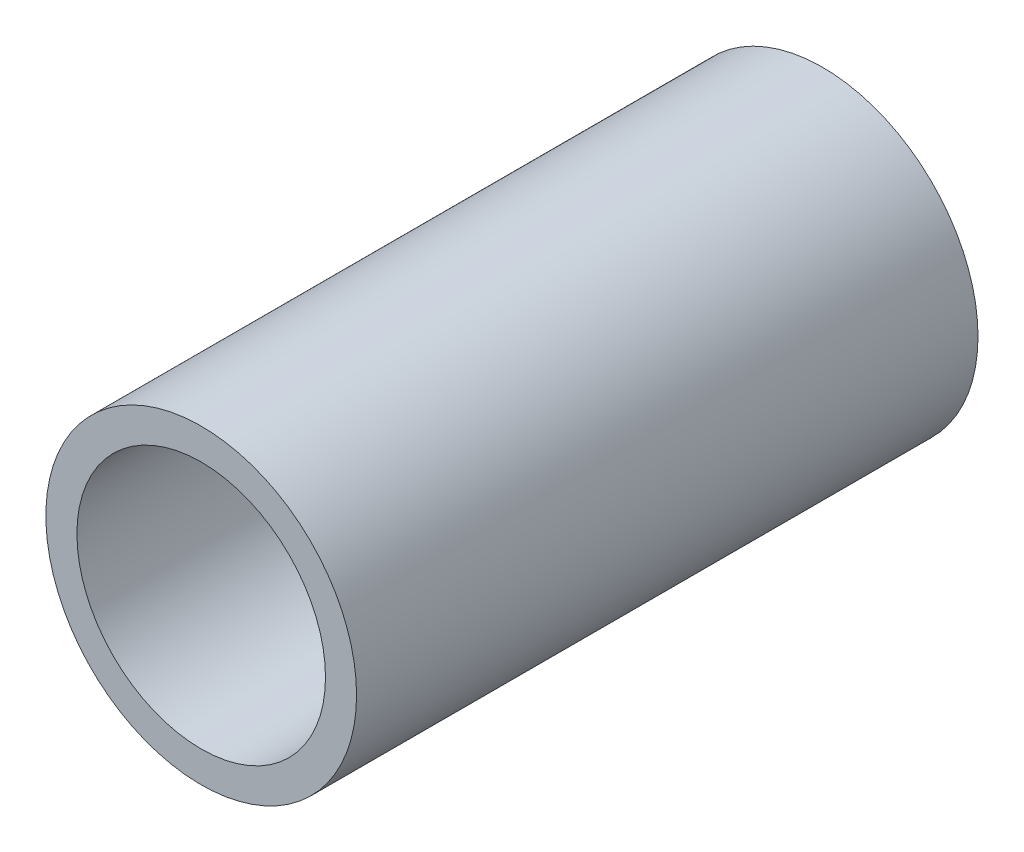
from build123d import *

# Parameters (mm, degrees)
SKETCH1_R           = 1.25
SKETCH1_R_2         = 1
BOSS_EXTRUDE1_DEPTH = 5


with BuildPart() as part:
    # Sketch1 → Boss-Extrude1 (new body)
    with BuildSketch(Plane.XY):
        Circle(SKETCH1_R)
        Circle(SKETCH1_R_2, mode=Mode.SUBTRACT)
    extrude(amount=BOSS_EXTRUDE1_DEPTH)


solid = part.part
